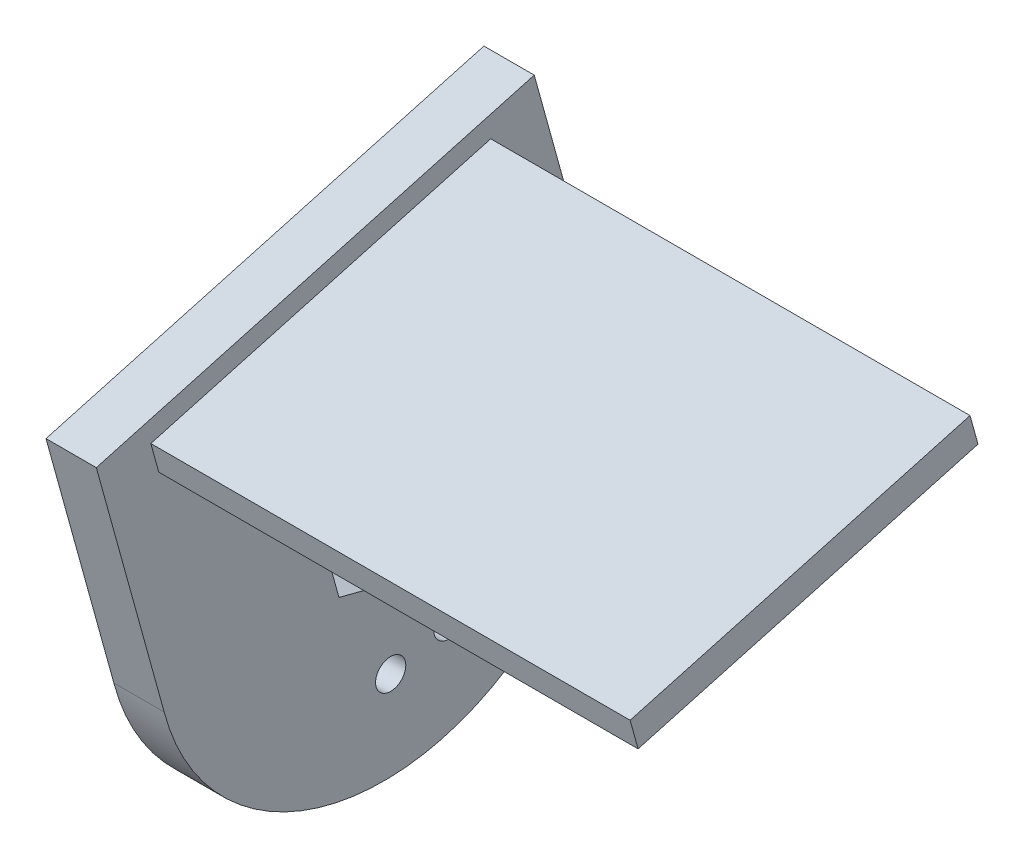
from build123d import *

# Parameters (mm, degrees)
SKETCH1_R           = 22.57
BOSS_EXTRUDE1_DEPTH = 5
BOSS_EXTRUDE2_DEPTH = 5
CUT_EXTRUDE2_DEPTH  = 5
SKETCH5_R           = 1.5
CUT_EXTRUDE3_DEPTH  = 5
BOSS_EXTRUDE3_DEPTH = 47.62
CUT_EXTRUDE5_DEPTH  = 47.62


with BuildPart() as part:
    # Sketch1 → Boss-Extrude1 (new body)
    with BuildSketch(Plane(origin=(0, 0, 0), x_dir=(0, 0, -1), z_dir=(1, 0, 0))):
        Circle(SKETCH1_R)
    extrude(amount=BOSS_EXTRUDE1_DEPTH)

    # Sketch3 → Boss-Extrude2 (add)
    with BuildSketch(Plane(origin=(5, 0, 0), x_dir=(0, 0, -1), z_dir=(1, 0, 0))):
        Polygon((21.833735154, 5.717771349), (14.930960802, 30.701130063), (-28.574903185, 18.68068215), (-21.833735154, -5.717771349), align=None)
    extrude(amount=-BOSS_EXTRUDE2_DEPTH)

    # Sketch4 → Cut-Extrude2 (cut)
    with BuildSketch(Plane.ZY):
        Polygon((4.470755169, -4.540778658), (6.167807255, 1.601398221), (1.697052086, 6.142176879), (-4.470755169, 4.540778658), (-6.167807255, -1.601398221), (-1.697052086, -6.142176879), align=None)
    extrude(amount=-CUT_EXTRUDE2_DEPTH, mode=Mode.SUBTRACT)

    # Sketch5 → Cut-Extrude3 (cut)
    with BuildSketch(Plane(origin=(5, 0, 0), x_dir=(0, 0, -1), z_dir=(1, 0, 0))):
        with Locations((0.669304585, -13.687213536)):
            Circle(SKETCH5_R)
        with Locations((6.452618137, -12.089313553)):
            Circle(SKETCH5_R)
    extrude(amount=-CUT_EXTRUDE3_DEPTH, mode=Mode.SUBTRACT)

    # Sketch6 → Boss-Extrude3 (add)
    with BuildSketch(Plane(origin=(5, 0, 0), x_dir=(0, 0, -1), z_dir=(1, 0, 0))):
        Polygon((10.64416617, 27.44177556), (-23.222841897, 18.084494285), (-22.406311475, 15.129208279), (11.460696592, 24.486489554), align=None)
    extrude(amount=BOSS_EXTRUDE3_DEPTH)

    # Sketch7 → Cut-Extrude5 (cut)
    with BuildSketch(Plane(origin=(52.62, 0, 0), x_dir=(0, 0, -1), z_dir=(1, 0, 0))):
        Polygon((11.460696592, 24.486489554), (10.64416617, 27.44177556), (-23.222841897, 18.084494285), (-22.406311475, 15.129208279), align=None)
        Polygon((11.399186479, 24.521368001), (10.609287723, 27.380265447), (-23.161331784, 18.049615839), (-22.371433028, 15.190718392), align=None, mode=Mode.SUBTRACT)
    extrude(amount=-CUT_EXTRUDE5_DEPTH, mode=Mode.SUBTRACT)


solid = part.part
